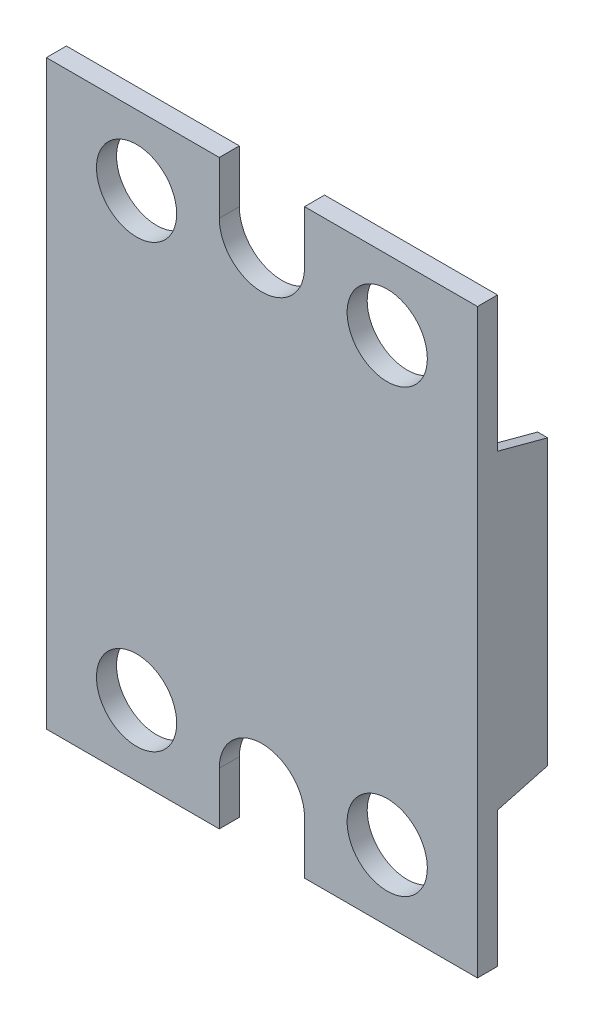
from build123d import *

# Parameters (mm, degrees)
SKETCH1_W                    = 43
SKETCH1_H                    = 58
BOSS_EXTRUDE1_DEPTH          = 2
CUT_EXTRUDE1_DEPTH           = 3
CUT_EXTRUDE2_DEPTH           = 3
SKETCH4_W                    = 1
SKETCH4_H                    = 31
BOSS_EXTRUDE2_DEPTH          = 5
SKETCH5_W                    = 1
SKETCH5_H                    = 31
BOSS_EXTRUDE3_DEPTH          = 5
DRAFT1_ANGLE                 = 15
F_8_0_8_DIAMETER_HOLE1_D     = 8
F_8_0_8_DIAMETER_HOLE1_DEPTH = 7


with BuildPart() as part:
    # Sketch1 → Boss-Extrude1 (new body)
    with BuildSketch(Plane(origin=(0, 0, -2), x_dir=(-1, 0, 0), z_dir=(0, 0, -1))):
        Rectangle(SKETCH1_W, SKETCH1_H)
    extrude(amount=-BOSS_EXTRUDE1_DEPTH)

    # Sketch2 → Cut-Extrude1 (cut, through all)
    with BuildSketch(Plane.XY):
        with BuildLine():
            Line((4.25, 29), (-4.25, 29))
            Line((-4.25, 29), (-4.25, 23.75))
            ThreePointArc((-4.25, 23.75), (0, 19.5), (4.25, 23.75))
            Line((4.25, 23.75), (4.25, 29))
        make_face()
    extrude(amount=-CUT_EXTRUDE1_DEPTH, mode=Mode.SUBTRACT)

    # Sketch3 → Cut-Extrude2 (cut, through all)
    with BuildSketch(Plane.XY):
        with BuildLine():
            Line((-4.25, -29), (4.25, -29))
            Line((4.25, -29), (4.25, -23.75))
            ThreePointArc((4.25, -23.75), (0, -19.5), (-4.25, -23.75))
            Line((-4.25, -23.75), (-4.25, -29))
        make_face()
    extrude(amount=-CUT_EXTRUDE2_DEPTH, mode=Mode.SUBTRACT)

    # Sketch4 → Boss-Extrude2 (add)
    with BuildSketch(Plane(origin=(0, 0, -2), x_dir=(-1, 0, 0), z_dir=(0, 0, -1))):
        with Locations((-21, 0)):
            Rectangle(SKETCH4_W, SKETCH4_H)
    extrude(amount=BOSS_EXTRUDE2_DEPTH)

    # Sketch5 → Boss-Extrude3 (add)
    with BuildSketch(Plane(origin=(0, 0, -2), x_dir=(-1, 0, 0), z_dir=(0, 0, -1))):
        with Locations((21, 0)):
            Rectangle(SKETCH5_W, SKETCH5_H)
    extrude(amount=BOSS_EXTRUDE3_DEPTH)

    # Draft1
    draft1_faces = [part.faces().sort_by_distance(p)[0] for p in [
        (21, -15.5, -4.5),
        (21, 15.5, -4.5),
        (-21, 15.5, -4.5),
        (-21, -15.5, -4.5),
    ]]
    draft(draft1_faces, Plane(origin=(0, 0, -2), x_dir=(-1, 0, 0), z_dir=(0, 0, -1)), DRAFT1_ANGLE)

    # Ø8.0 (8) Diameter Hole1
    with Locations(Plane.XY):
        with Locations((12.5, 22), (-12.5, 22), (-12.5, -22), (12.5, -22)):
            Hole(F_8_0_8_DIAMETER_HOLE1_D / 2, depth=F_8_0_8_DIAMETER_HOLE1_DEPTH)


solid = part.part
